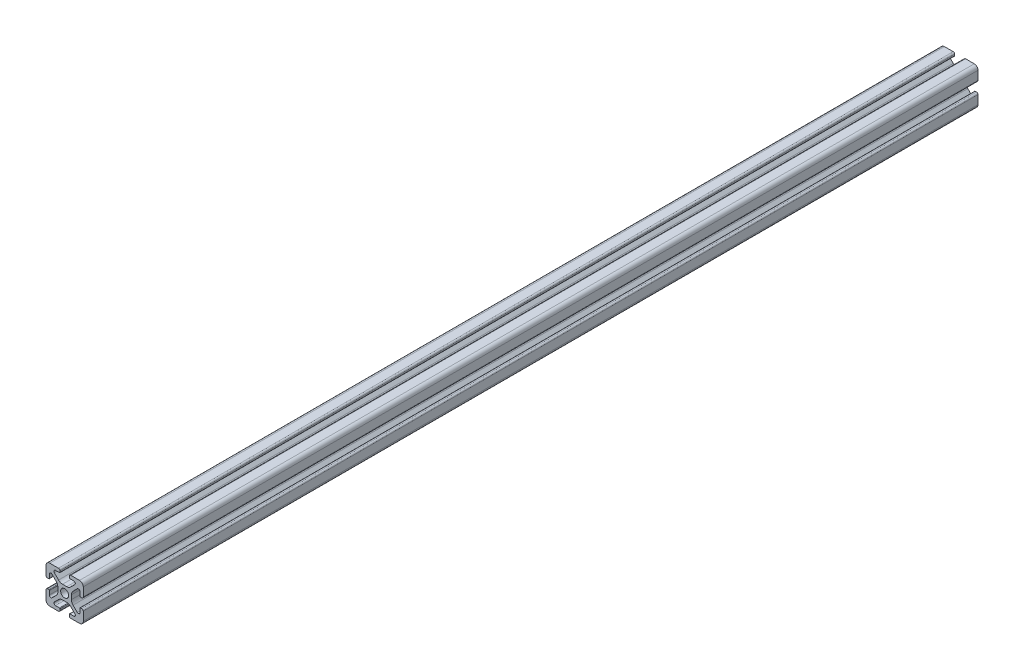
from build123d import *

# Parameters (mm, degrees)
SKETCH4_W              = 20
SKETCH4_H              = 20
BODY_DEPTH             = 480
SKETCH16_OUTSIDE_W     = 118.166
SKETCH16_OUTSIDE_H     = 118.166
SKETCH16_OUTSIDE_R     = 2.15
CUT_PROFILE_DEPTH      = 26
CUT_PROFILE_DEPTH_BACK = 456


with BuildPart() as part:
    # Sketch4 → Body (new body)
    with BuildSketch(Plane.XY.offset(25)):
        Rectangle(SKETCH4_W, SKETCH4_H)
    extrude(amount=-BODY_DEPTH)

    # Sketch16 outside → Cut-Profile (cut, two sides)
    with BuildSketch(Plane.XY) as cut_profile_sk:
        Rectangle(SKETCH16_OUTSIDE_W, SKETCH16_OUTSIDE_H)
        with BuildLine():
            Line((4.917588389, -8.199999991), (2.799999989, -8.199999991))
            ThreePointArc((2.799999989, -8.199999991), (2.587867955, -8.287867957), (2.499999989, -8.499999991))
            Line((2.499999989, -8.499999991), (2.499999989, -9.199999991))
            ThreePointArc((2.499999989, -9.199999991), (2.734314564, -9.765685416), (3.299999989, -9.999999991))
            Line((3.299999989, -9.999999991), (7.999999989, -9.999999991))
            ThreePointArc((7.999999989, -9.999999991), (9.414213552, -9.414213554), (9.999999989, -7.999999991))
            Line((9.999999989, -7.999999991), (9.999999989, -3.299999991))
            ThreePointArc((9.999999989, -3.299999991), (9.765685414, -2.734314566), (9.199999989, -2.499999991))
            Line((9.199999989, -2.499999991), (8.499999989, -2.499999991))
            ThreePointArc((8.499999989, -2.499999991), (8.287867955, -2.587867957), (8.199999989, -2.799999991))
            Line((8.199999989, -2.799999991), (8.199999989, -4.917588391))
            ThreePointArc((8.199999989, -4.917588391), (7.686138511, -5.686636441), (6.778984485, -5.506192286))
            Line((6.778984485, -5.506192286), (4.528679645, -3.255887446))
            ThreePointArc((4.528679645, -3.255887446), (3.878361392, -2.282617401), (3.64999999, -1.134567106))
            Line((3.64999999, -1.134567106), (3.64999999, 1.134567104))
            ThreePointArc((3.64999999, 1.134567104), (3.878361393, 2.282617402), (4.528679647, 3.255887448))
            Line((4.528679647, 3.255887448), (6.778984487, 5.506192288))
            ThreePointArc((6.778984487, 5.506192288), (7.686138506, 5.686636442), (8.199999981, 4.917588398))
            Line((8.199999981, 4.917588398), (8.199999981, 2.799999998))
            ThreePointArc((8.199999981, 2.799999998), (8.287867946, 2.587867964), (8.499999981, 2.499999998))
            Line((8.499999981, 2.499999998), (9.199999981, 2.499999998))
            ThreePointArc((9.199999981, 2.499999998), (9.765685406, 2.734314573), (9.999999981, 3.299999998))
            Line((9.999999981, 3.299999998), (9.999999981, 7.999999998))
            ThreePointArc((9.999999981, 7.999999998), (9.414213543, 9.41421356), (7.999999981, 9.999999998))
            Line((7.999999981, 9.999999998), (3.299999981, 9.999999998))
            ThreePointArc((3.299999981, 9.999999998), (2.734314556, 9.765685423), (2.499999981, 9.199999998))
            Line((2.499999981, 9.199999998), (2.499999981, 8.499999998))
            ThreePointArc((2.499999981, 8.499999998), (2.587867946, 8.287867964), (2.799999981, 8.199999998))
            Line((2.799999981, 8.199999998), (4.917588381, 8.199999998))
            ThreePointArc((4.917588381, 8.199999998), (5.68663643, 7.68613852), (5.506192275, 6.778984494))
            Line((5.506192275, 6.778984494), (3.255887435, 4.528679654))
            ThreePointArc((3.255887435, 4.528679654), (2.28261739, 3.878361401), (1.134567095, 3.649999999))
            Line((1.134567095, 3.649999999), (-1.134567115, 3.649999999))
            ThreePointArc((-1.134567115, 3.649999999), (-2.282617412, 3.878361401), (-3.255887459, 4.528679655))
            Line((-3.255887459, 4.528679655), (-5.506192299, 6.778984495))
            ThreePointArc((-5.506192299, 6.778984495), (-5.686636452, 7.686138515), (-4.917588409, 8.199999989))
            Line((-4.917588409, 8.199999989), (-2.800000009, 8.199999989))
            ThreePointArc((-2.800000009, 8.199999989), (-2.587867974, 8.287867955), (-2.500000009, 8.499999989))
            Line((-2.500000009, 8.499999989), (-2.500000009, 9.199999989))
            ThreePointArc((-2.500000009, 9.199999989), (-2.734314584, 9.765685414), (-3.300000009, 9.999999989))
            Line((-3.300000009, 9.999999989), (-8.000000009, 9.999999989))
            ThreePointArc((-8.000000009, 9.999999989), (-9.414213571, 9.414213552), (-10.000000009, 7.999999989))
            Line((-10.000000009, 7.999999989), (-10.000000009, 3.299999989))
            ThreePointArc((-10.000000009, 3.299999989), (-9.765685434, 2.734314564), (-9.200000009, 2.499999989))
            Line((-9.200000009, 2.499999989), (-8.500000009, 2.499999989))
            ThreePointArc((-8.500000009, 2.499999989), (-8.287867974, 2.587867955), (-8.200000009, 2.799999989))
            Line((-8.200000009, 2.799999989), (-8.200000009, 4.917588389))
            ThreePointArc((-8.200000009, 4.917588389), (-7.686138531, 5.686636438), (-6.778984504, 5.506192284))
            Line((-6.778984504, 5.506192284), (-4.528679664, 3.255887444))
            ThreePointArc((-4.528679664, 3.255887444), (-3.878361412, 2.282617399), (-3.650000009, 1.134567104))
            Line((-3.650000009, 1.134567104), (-3.650000009, -1.134567106))
            ThreePointArc((-3.650000009, -1.134567106), (-3.878361412, -2.282617404), (-4.528679666, -3.25588745))
            Line((-4.528679666, -3.25588745), (-6.778984506, -5.50619229))
            ThreePointArc((-6.778984506, -5.50619229), (-7.686138526, -5.686636444), (-8.2, -4.9175884))
            Line((-8.2, -4.9175884), (-8.2, -2.8))
            ThreePointArc((-8.2, -2.8), (-8.287867966, -2.587867966), (-8.5, -2.5))
            Line((-8.5, -2.5), (-9.2, -2.5))
            ThreePointArc((-9.2, -2.5), (-9.765685425, -2.734314575), (-10, -3.3))
            Line((-10, -3.3), (-10, -8))
            ThreePointArc((-10, -8), (-9.414213562, -9.414213562), (-8, -10))
            Line((-8, -10), (-3.3, -10))
            ThreePointArc((-3.3, -10), (-2.734314575, -9.765685425), (-2.5, -9.2))
            Line((-2.5, -9.2), (-2.5, -8.5))
            ThreePointArc((-2.5, -8.5), (-2.587867966, -8.287867966), (-2.8, -8.2))
            Line((-2.8, -8.2), (-4.9175884, -8.2))
            ThreePointArc((-4.9175884, -8.2), (-5.686636449, -7.686138522), (-5.506192294, -6.778984496))
            Line((-5.506192294, -6.778984496), (-3.255887454, -4.528679656))
            ThreePointArc((-3.255887454, -4.528679656), (-2.282617409, -3.878361403), (-1.134567114, -3.650000001))
            Line((-1.134567114, -3.650000001), (1.134567096, -3.650000001))
            ThreePointArc((1.134567096, -3.650000001), (2.282617393, -3.878361403), (3.255887439, -4.528679657))
            Line((3.255887439, -4.528679657), (5.506192279, -6.778984497))
            ThreePointArc((5.506192279, -6.778984497), (5.686636433, -7.686138517), (4.917588389, -8.199999991))
        make_face(mode=Mode.SUBTRACT)
        Circle(SKETCH16_OUTSIDE_R)
    extrude(amount=CUT_PROFILE_DEPTH, mode=Mode.SUBTRACT)
    extrude(cut_profile_sk.sketch, amount=-CUT_PROFILE_DEPTH_BACK, mode=Mode.SUBTRACT)


solid = part.part
